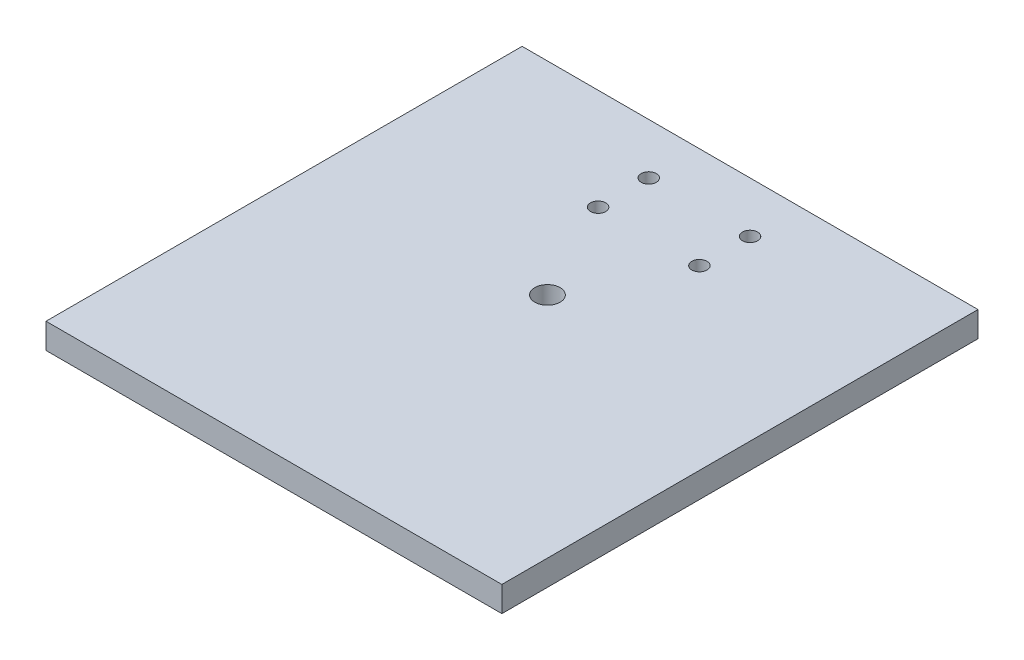
from build123d import *

# Parameters (mm, degrees)
SKETCH1_W           = 114.3
SKETCH1_H           = 119.38
SKETCH1_R           = 1.905
SKETCH1_R_2         = 3.175
BOSS_EXTRUDE1_DEPTH = 6.35


with BuildPart() as part:
    # Sketch1 → Boss-Extrude1 (new body)
    with BuildSketch(Plane(origin=(0, 0, 0), x_dir=(1, 0, 0), z_dir=(0, 1, 0))):
        with Locations((57.15, 59.69)):
            Rectangle(SKETCH1_W, SKETCH1_H)
        with Locations((44.45, 106.68)):
            Circle(SKETCH1_R, mode=Mode.SUBTRACT)
        with Locations((69.85, 106.68)):
            Circle(SKETCH1_R, mode=Mode.SUBTRACT)
        with Locations((44.45, 93.98)):
            Circle(SKETCH1_R, mode=Mode.SUBTRACT)
        with Locations((69.85, 93.98)):
            Circle(SKETCH1_R, mode=Mode.SUBTRACT)
        with Locations((57.15, 68.58)):
            Circle(SKETCH1_R_2, mode=Mode.SUBTRACT)
    extrude(amount=BOSS_EXTRUDE1_DEPTH)


solid = part.part
